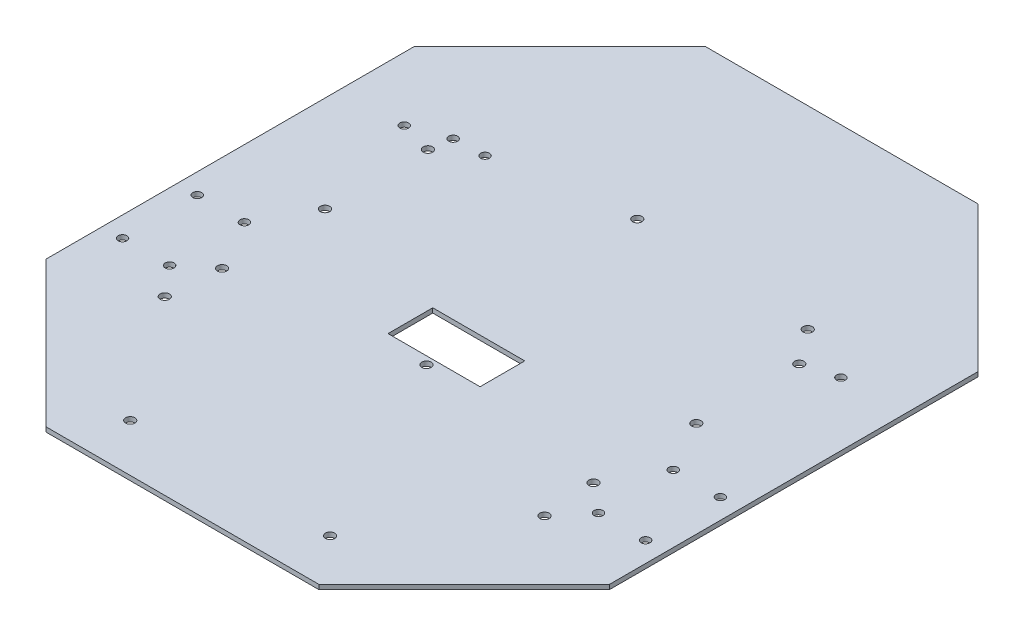
from build123d import *

# Parameters (mm, degrees)
BOSS_EXTRUDE2_DEPTH             = 3.12
CUT_EXTRUDE2_DEPTH              = 4.12
CUT_EXTRUDE3_DEPTH              = 4.12
F_1_4_0_25_DIAMETER_HOLE1_D     = 6.35
F_1_4_0_25_DIAMETER_HOLE1_DEPTH = 3.12
CUT_EXTRUDE4_REACH              = 5.12
SKETCH22_W                      = 62.565541267
SKETCH22_H                      = 30.394221155
F_6_0MM_DOWEL_HOLE2_D           = 6
F_6_0MM_DOWEL_HOLE2_DEPTH       = 3.12
F_6_0MM_DOWEL_HOLE1_D           = 6
F_6_0MM_DOWEL_HOLE1_DEPTH       = 3.12
F_6_0MM_DOWEL_HOLE3_D           = 6
F_6_0MM_DOWEL_HOLE3_DEPTH       = 3.12


with BuildPart() as part:
    # Sketch14 → Boss-Extrude2 (new body)
    with BuildSketch(Plane(origin=(0, 0, 0), x_dir=(1, 0, 0), z_dir=(0, 1, 0))):
        Polygon((224, 92.783837972), (92.783837972, 224), (-92.783837972, 224), (-224, 92.783837972), (-224, -92.783837972), (-92.783837972, -224), (92.783837972, -224), (224, -92.783837972), align=None)
    extrude(amount=BOSS_EXTRUDE2_DEPTH)

    # Sketch17 → Cut-Extrude2 (cut)
    with BuildSketch(Plane.XZ):
        Polygon((191.5, 125.283837972), (191.5, -125.741978826), (224, -92.783837972), (224, 92.783837972), align=None)
    extrude(amount=-CUT_EXTRUDE2_DEPTH, mode=Mode.SUBTRACT)

    # Sketch18 → Cut-Extrude3 (cut)
    with BuildSketch(Plane.XZ):
        Polygon((-191.5, 125.283837972), (-224, 92.783837972), (-224, -92.783837972), (-191.5, -125.283837972), align=None)
    extrude(amount=-CUT_EXTRUDE3_DEPTH, mode=Mode.SUBTRACT)

    # 1/4 (0.25) Diameter Hole1
    with Locations(Plane(origin=(0, 3.12, 0), x_dir=(1, 0, 0), z_dir=(0, 1, 0))):
        with Locations((67.963501684, -191.608983424), (-67.926498316, -191.608983424), (-129.064298316, -106.988883424), (-126.194098316, -70.895483424), (-126.194098316, -0.918483424), (-126.194098316, 69.058516576), (-14.103898316, 99.259116576), (108.730501684, 92.299516576), (126.231101684, 69.058516576), (126.231101684, -0.918483424), (129.101301684, -106.988883424), (126.231101684, -70.895483424), (0.018501684, -58.195483424)):
            Hole(F_1_4_0_25_DIAMETER_HOLE1_D / 2, depth=F_1_4_0_25_DIAMETER_HOLE1_DEPTH)

    # Sketch22 → Cut-Extrude4 (cut, up to next)
    with BuildSketch(Plane(origin=(0, 3.12, 0), x_dir=(1, 0, 0), z_dir=(0, 1, 0)), mode=Mode.PRIVATE) as cut_extrude4_sk1:
        with Locations((-0.116925735, -37.67927099)):
            Rectangle(SKETCH22_W, SKETCH22_H)
    cut_extrude4_tool1 = extrude(cut_extrude4_sk1.sketch, amount=-CUT_EXTRUDE4_REACH, mode=Mode.PRIVATE) & part.part
    add(cut_extrude4_tool1.solids().sort_by_distance((-0.116926, 3.12, 37.679271))[0], mode=Mode.SUBTRACT)

    # Ø6.0mm Dowel Hole2
    with Locations(Plane(origin=(0, 3.12, 0), x_dir=(1, 0, 0), z_dir=(0, 1, 0))):
        with Locations((-177.781498316, -36.158906441), (-177.781498316, -86.988906441), (-145.741498316, -36.158906441), (-145.741498316, -86.988906441), (145.778501684, -86.988906441), (177.818501684, -86.988906441), (177.818501684, -36.158906441), (145.778501684, -36.158906441)):
            Hole(F_6_0MM_DOWEL_HOLE2_D / 2, depth=F_6_0MM_DOWEL_HOLE2_DEPTH)

    # Ø6.0mm Dowel Hole1
    with Locations(Plane(origin=(0, 3.12, 0), x_dir=(1, 0, 0), z_dir=(0, 1, 0))):
        with Locations((-103.151498316, 84.807287956), (-124.001498316, 84.003641445)):
            Hole(F_6_0MM_DOWEL_HOLE1_D / 2, depth=F_6_0MM_DOWEL_HOLE1_DEPTH)

    # Ø6.0mm Dowel Hole3
    with Locations(Plane(origin=(0, 3.12, 0), x_dir=(1, 0, 0), z_dir=(0, 1, 0))):
        with Locations((-148.396200775, 75.127115617), (148.417336994, 75.150841329)):
            Hole(F_6_0MM_DOWEL_HOLE3_D / 2, depth=F_6_0MM_DOWEL_HOLE3_DEPTH)


solid = part.part
